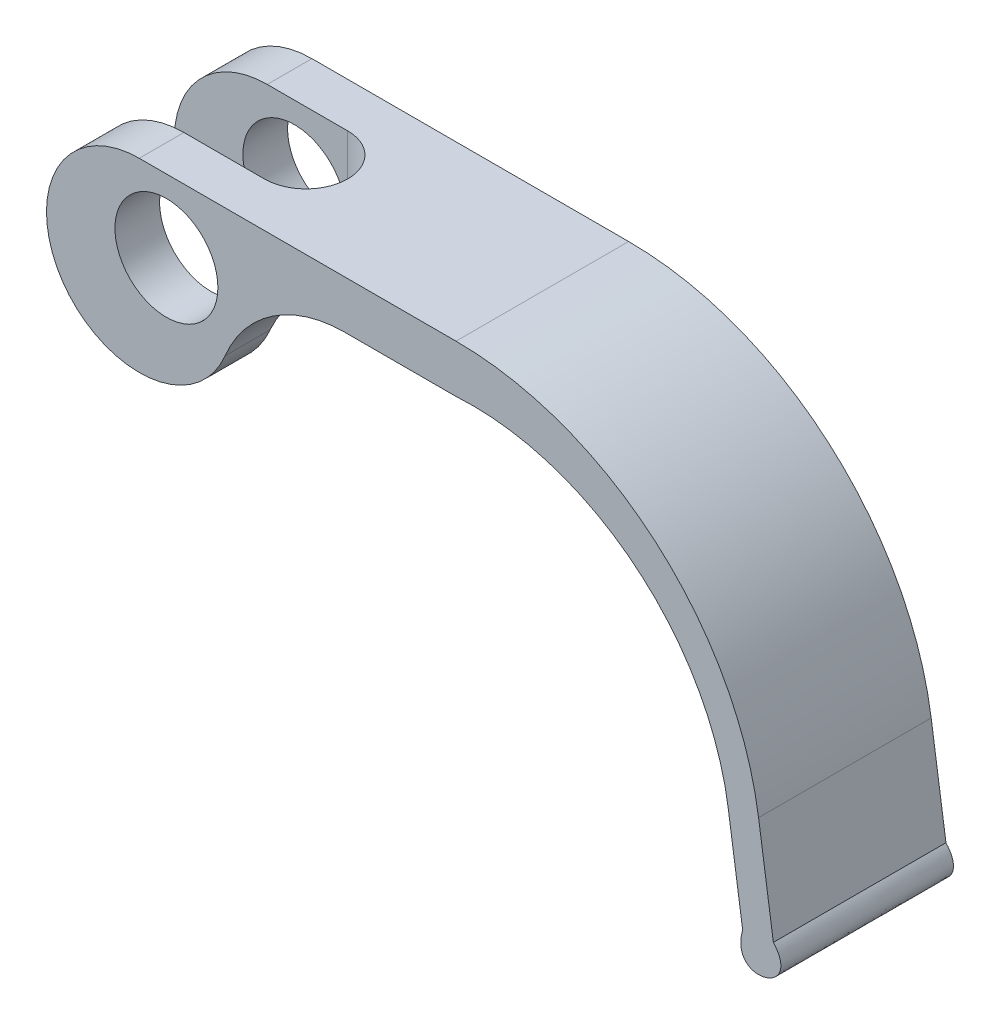
from build123d import *

# Parameters (mm, degrees)
SKETCH1_R           = 4.1275
BOSS_EXTRUDE1_DEPTH = 13.843
CUT_EXTRUDE1_DEPTH  = 21.463


with BuildPart() as part:
    # Sketch1 → Boss-Extrude1 (new body)
    with BuildSketch(Plane.XY):
        with BuildLine():
            Line((-2.174766514, 5.8293), (23.225233486, 5.8293))
            ThreePointArc((23.225233486, 5.8293), (39.256887261, -0.136207699), (47.489215864, -15.130538982))
            Line((47.489215864, -15.130538982), (48.675112128, -23.2029))
            add(Edge.make_bspline(
                [(46.212346009, -23.56470061), (45.056877099, -27.681849857), (51.170161996, -26.006789114), (48.675112128, -23.2029)],
                knots=[0, 0, 0, 0, 1, 1, 1, 1], degree=3))
            Line((46.212346009, -23.56470061), (45.055850098, -15.692466932))
            ThreePointArc((45.055850098, -15.692466932), (37.59061151, -2.592519956), (23.225233486, 1.98725211))
            Line((23.225233486, 1.98725211), (14.323446957, 1.98725211))
            ThreePointArc((14.323446957, 1.98725211), (8.536644874, 0.229383426), (4.70535824, -4.450191704))
            ThreePointArc((4.70535824, -4.450191704), (-8.359507137, -5.752383574), (-2.174766514, 5.8293))
        make_face()
        Circle(SKETCH1_R, mode=Mode.SUBTRACT)
    extrude(amount=BOSS_EXTRUDE1_DEPTH)

    # Sketch2 → Cut-Extrude1 (cut)
    with BuildSketch(Plane(origin=(0, 5.8293, 0), x_dir=(1, 0, 0), z_dir=(0, 1, 0))):
        with BuildLine():
            Line((4.276833486, -3.5814), (-9.616966514, -3.5814))
            Line((-9.616966514, -3.5814), (-9.616966514, -10.2616))
            Line((-9.616966514, -10.2616), (4.276833486, -10.2616))
            ThreePointArc((4.276833486, -10.2616), (7.616933486, -6.9215), (4.276833486, -3.5814))
        make_face()
    extrude(amount=-CUT_EXTRUDE1_DEPTH, mode=Mode.SUBTRACT)


solid = part.part
